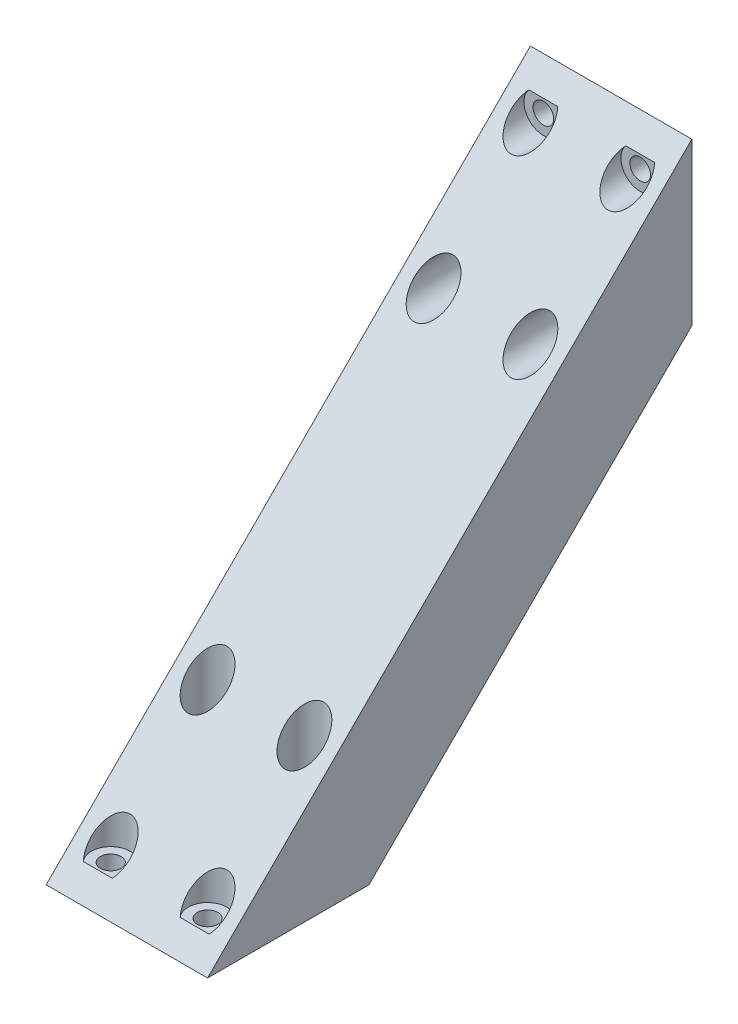
from build123d import *

# Parameters (mm, degrees)
BOSS_EXTRUDE1_DEPTH = 25
CUT_EXTRUDE2_REACH  = 113.972
CUT_EXTRUDE2_START  = -3
SKETCH2_R           = 3
SKETCH2_R_2         = 1.6
CUT_EXTRUDE3_REACH  = 110.972
SKETCH2_3_R         = 1.6
CUT_EXTRUDE7_REACH  = 98.541
CUT_EXTRUDE7_START  = -3
SKETCH3_R           = 3
SKETCH3_R_2         = 1.6
CUT_EXTRUDE8_REACH  = 95.541
SKETCH3_3_R         = 1.6


with BuildPart() as part:
    # Sketch1 → Boss-Extrude1 (new body)
    with BuildSketch(Plane(origin=(0, 0, 0), x_dir=(0, 0, -1), z_dir=(1, 0, 0))):
        Polygon((0, 0), (-50, -50), (-75, -50), (0, 25), align=None)
    extrude(amount=BOSS_EXTRUDE1_DEPTH)

    # Sketch2 → Cut-Extrude2 (cut, up to next)
    with BuildSketch(Plane.XZ.offset(50).offset(CUT_EXTRUDE2_START), mode=Mode.PRIVATE) as cut_extrude2_sk1:
        with Locations((20, 70)):
            Circle(SKETCH2_R)
        with Locations((20, 70)):
            Circle(SKETCH2_R_2, mode=Mode.SUBTRACT)
    cut_extrude2_tool1 = extrude(cut_extrude2_sk1.sketch, amount=-CUT_EXTRUDE2_REACH, mode=Mode.PRIVATE) & part.part
    # Sketch2 → Cut-Extrude2 (cut, up to next)
    with BuildSketch(Plane.XZ.offset(50).offset(CUT_EXTRUDE2_START), mode=Mode.PRIVATE) as cut_extrude2_sk2:
        with Locations((5, 70)):
            Circle(SKETCH2_R)
        with Locations((5, 70)):
            Circle(SKETCH2_R_2, mode=Mode.SUBTRACT)
    cut_extrude2_tool2 = extrude(cut_extrude2_sk2.sketch, amount=-CUT_EXTRUDE2_REACH, mode=Mode.PRIVATE) & part.part
    # Sketch2 → Cut-Extrude2 (cut, up to next)
    with BuildSketch(Plane.XZ.offset(50).offset(CUT_EXTRUDE2_START), mode=Mode.PRIVATE) as cut_extrude2_sk3:
        with Locations((5, 55)):
            Circle(SKETCH2_R)
        with Locations((5, 55)):
            Circle(SKETCH2_R_2, mode=Mode.SUBTRACT)
    cut_extrude2_tool3 = extrude(cut_extrude2_sk3.sketch, amount=-CUT_EXTRUDE2_REACH, mode=Mode.PRIVATE) & part.part
    # Sketch2 → Cut-Extrude2 (cut, up to next)
    with BuildSketch(Plane.XZ.offset(50).offset(CUT_EXTRUDE2_START), mode=Mode.PRIVATE) as cut_extrude2_sk4:
        with Locations((20, 55)):
            Circle(SKETCH2_R)
        with Locations((20, 55)):
            Circle(SKETCH2_R_2, mode=Mode.SUBTRACT)
    cut_extrude2_tool4 = extrude(cut_extrude2_sk4.sketch, amount=-CUT_EXTRUDE2_REACH, mode=Mode.PRIVATE) & part.part
    add(cut_extrude2_tool1.solids().sort_by_distance((17.084853, -47, 70))[0], mode=Mode.SUBTRACT)
    add(cut_extrude2_tool2.solids().sort_by_distance((2.084853, -47, 70))[0], mode=Mode.SUBTRACT)
    add(cut_extrude2_tool3.solids().sort_by_distance((2.084853, -47, 55))[0], mode=Mode.SUBTRACT)
    add(cut_extrude2_tool4.solids().sort_by_distance((17.084853, -47, 55))[0], mode=Mode.SUBTRACT)

    # Sketch2_3 → Cut-Extrude3 (cut, up to next)
    with BuildSketch(Plane.XZ.offset(50), mode=Mode.PRIVATE) as cut_extrude3_sk1:
        with Locations((20, 70)):
            Circle(SKETCH2_3_R)
    cut_extrude3_tool1 = extrude(cut_extrude3_sk1.sketch, amount=-CUT_EXTRUDE3_REACH, mode=Mode.PRIVATE) & part.part
    # Sketch2_3 → Cut-Extrude3 (cut, up to next)
    with BuildSketch(Plane.XZ.offset(50), mode=Mode.PRIVATE) as cut_extrude3_sk2:
        with Locations((5, 70)):
            Circle(SKETCH2_3_R)
    cut_extrude3_tool2 = extrude(cut_extrude3_sk2.sketch, amount=-CUT_EXTRUDE3_REACH, mode=Mode.PRIVATE) & part.part
    # Sketch2_3 → Cut-Extrude3 (cut, up to next)
    with BuildSketch(Plane.XZ.offset(50), mode=Mode.PRIVATE) as cut_extrude3_sk3:
        with Locations((5, 55)):
            Circle(SKETCH2_3_R)
    cut_extrude3_tool3 = extrude(cut_extrude3_sk3.sketch, amount=-CUT_EXTRUDE3_REACH, mode=Mode.PRIVATE) & part.part
    # Sketch2_3 → Cut-Extrude3 (cut, up to next)
    with BuildSketch(Plane.XZ.offset(50), mode=Mode.PRIVATE) as cut_extrude3_sk4:
        with Locations((20, 55)):
            Circle(SKETCH2_3_R)
    cut_extrude3_tool4 = extrude(cut_extrude3_sk4.sketch, amount=-CUT_EXTRUDE3_REACH, mode=Mode.PRIVATE) & part.part
    add(cut_extrude3_tool1.solids().sort_by_distance((20, -50, 70))[0], mode=Mode.SUBTRACT)
    add(cut_extrude3_tool2.solids().sort_by_distance((5, -50, 70))[0], mode=Mode.SUBTRACT)
    add(cut_extrude3_tool3.solids().sort_by_distance((5, -50, 55))[0], mode=Mode.SUBTRACT)
    add(cut_extrude3_tool4.solids().sort_by_distance((20, -50, 55))[0], mode=Mode.SUBTRACT)

    # Sketch3 → Cut-Extrude7 (cut, up to next)
    with BuildSketch(Plane(origin=(0, 0, 0), x_dir=(-1, 0, 0), z_dir=(0, 0, -1)).offset(CUT_EXTRUDE7_START), mode=Mode.PRIVATE) as cut_extrude7_sk1:
        with Locations((-20, 20)):
            Circle(SKETCH3_R)
        with Locations((-20, 20)):
            Circle(SKETCH3_R_2, mode=Mode.SUBTRACT)
    cut_extrude7_tool1 = extrude(cut_extrude7_sk1.sketch, amount=-CUT_EXTRUDE7_REACH, mode=Mode.PRIVATE) & part.part
    # Sketch3 → Cut-Extrude7 (cut, up to next)
    with BuildSketch(Plane(origin=(0, 0, 0), x_dir=(-1, 0, 0), z_dir=(0, 0, -1)).offset(CUT_EXTRUDE7_START), mode=Mode.PRIVATE) as cut_extrude7_sk2:
        with Locations((-20, 5)):
            Circle(SKETCH3_R)
        with Locations((-20, 5)):
            Circle(SKETCH3_R_2, mode=Mode.SUBTRACT)
    cut_extrude7_tool2 = extrude(cut_extrude7_sk2.sketch, amount=-CUT_EXTRUDE7_REACH, mode=Mode.PRIVATE) & part.part
    # Sketch3 → Cut-Extrude7 (cut, up to next)
    with BuildSketch(Plane(origin=(0, 0, 0), x_dir=(-1, 0, 0), z_dir=(0, 0, -1)).offset(CUT_EXTRUDE7_START), mode=Mode.PRIVATE) as cut_extrude7_sk3:
        with Locations((-5, 5)):
            Circle(SKETCH3_R)
        with Locations((-5, 5)):
            Circle(SKETCH3_R_2, mode=Mode.SUBTRACT)
    cut_extrude7_tool3 = extrude(cut_extrude7_sk3.sketch, amount=-CUT_EXTRUDE7_REACH, mode=Mode.PRIVATE) & part.part
    # Sketch3 → Cut-Extrude7 (cut, up to next)
    with BuildSketch(Plane(origin=(0, 0, 0), x_dir=(-1, 0, 0), z_dir=(0, 0, -1)).offset(CUT_EXTRUDE7_START), mode=Mode.PRIVATE) as cut_extrude7_sk4:
        with Locations((-5, 20)):
            Circle(SKETCH3_R)
        with Locations((-5, 20)):
            Circle(SKETCH3_R_2, mode=Mode.SUBTRACT)
    cut_extrude7_tool4 = extrude(cut_extrude7_sk4.sketch, amount=-CUT_EXTRUDE7_REACH, mode=Mode.PRIVATE) & part.part
    add(cut_extrude7_tool1.solids().sort_by_distance((22.915147, 20, 3))[0], mode=Mode.SUBTRACT)
    add(cut_extrude7_tool2.solids().sort_by_distance((22.915147, 5, 3))[0], mode=Mode.SUBTRACT)
    add(cut_extrude7_tool3.solids().sort_by_distance((7.915147, 5, 3))[0], mode=Mode.SUBTRACT)
    add(cut_extrude7_tool4.solids().sort_by_distance((7.915147, 20, 3))[0], mode=Mode.SUBTRACT)

    # Sketch3_3 → Cut-Extrude8 (cut, up to next)
    with BuildSketch(Plane(origin=(0, 0, 0), x_dir=(-1, 0, 0), z_dir=(0, 0, -1)), mode=Mode.PRIVATE) as cut_extrude8_sk1:
        with Locations((-20, 20)):
            Circle(SKETCH3_3_R)
    cut_extrude8_tool1 = extrude(cut_extrude8_sk1.sketch, amount=-CUT_EXTRUDE8_REACH, mode=Mode.PRIVATE) & part.part
    # Sketch3_3 → Cut-Extrude8 (cut, up to next)
    with BuildSketch(Plane(origin=(0, 0, 0), x_dir=(-1, 0, 0), z_dir=(0, 0, -1)), mode=Mode.PRIVATE) as cut_extrude8_sk2:
        with Locations((-20, 5)):
            Circle(SKETCH3_3_R)
    cut_extrude8_tool2 = extrude(cut_extrude8_sk2.sketch, amount=-CUT_EXTRUDE8_REACH, mode=Mode.PRIVATE) & part.part
    # Sketch3_3 → Cut-Extrude8 (cut, up to next)
    with BuildSketch(Plane(origin=(0, 0, 0), x_dir=(-1, 0, 0), z_dir=(0, 0, -1)), mode=Mode.PRIVATE) as cut_extrude8_sk3:
        with Locations((-5, 5)):
            Circle(SKETCH3_3_R)
    cut_extrude8_tool3 = extrude(cut_extrude8_sk3.sketch, amount=-CUT_EXTRUDE8_REACH, mode=Mode.PRIVATE) & part.part
    # Sketch3_3 → Cut-Extrude8 (cut, up to next)
    with BuildSketch(Plane(origin=(0, 0, 0), x_dir=(-1, 0, 0), z_dir=(0, 0, -1)), mode=Mode.PRIVATE) as cut_extrude8_sk4:
        with Locations((-5, 20)):
            Circle(SKETCH3_3_R)
    cut_extrude8_tool4 = extrude(cut_extrude8_sk4.sketch, amount=-CUT_EXTRUDE8_REACH, mode=Mode.PRIVATE) & part.part
    add(cut_extrude8_tool1.solids().sort_by_distance((20, 20, 0))[0], mode=Mode.SUBTRACT)
    add(cut_extrude8_tool2.solids().sort_by_distance((20, 5, 0))[0], mode=Mode.SUBTRACT)
    add(cut_extrude8_tool3.solids().sort_by_distance((5, 5, 0))[0], mode=Mode.SUBTRACT)
    add(cut_extrude8_tool4.solids().sort_by_distance((5, 20, 0))[0], mode=Mode.SUBTRACT)


solid = part.part
